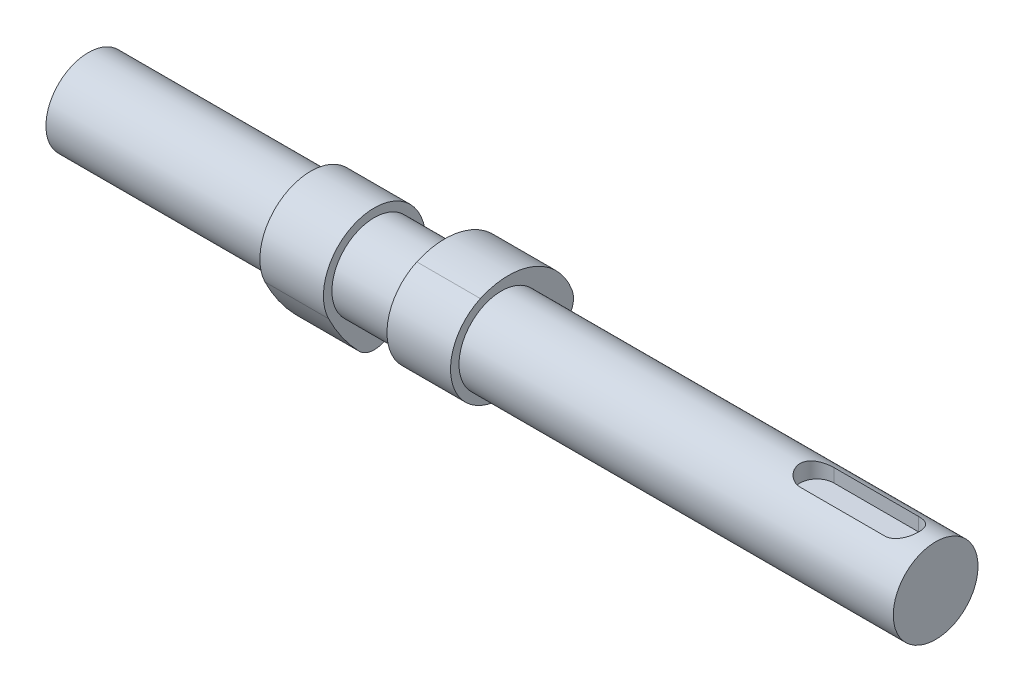
from build123d import *

# Parameters (mm, degrees)
SKETCH1_R                = 10
BOSS_EXTRUDE1_DEPTH      = 125
BOSS_EXTRUDE1_DEPTH_BACK = 75
BOSS_EXTRUDE2_START      = 15
BOSS_EXTRUDE2_DEPTH      = 7.5
LPATTERN1_COUNT          = 2
LPATTERN1_PITCH          = 30
BODY_MOVE_COPY1_ANGLE    = 90
CUT_EXTRUDE1_DEPTH       = 4


with BuildPart() as part:
    # Sketch1 → Boss-Extrude1 (new body, two sides)
    with BuildSketch(Plane(origin=(0, 0, 0), x_dir=(0, 0, -1), z_dir=(1, 0, 0))) as boss_extrude1_sk:
        Circle(SKETCH1_R)
    extrude(amount=BOSS_EXTRUDE1_DEPTH)
    extrude(boss_extrude1_sk.sketch, amount=-BOSS_EXTRUDE1_DEPTH_BACK)

    # Sketch3 → Cut-Extrude1 (cut)
    with BuildSketch(Plane(origin=(0, 10, 0), x_dir=(1, 0, 0), z_dir=(0, 1, 0))):
        with BuildLine():
            Line((97, 4), (117, 4))
            ThreePointArc((117, 4), (121, 0), (117, -4))
            Line((117, -4), (97, -4))
            ThreePointArc((97, -4), (93, 0), (97, 4))
        make_face()
    extrude(amount=-CUT_EXTRUDE1_DEPTH, mode=Mode.SUBTRACT)


with BuildPart() as body_2:
    # Sketch2 → Boss-Extrude2 (new body, symmetric)
    with BuildSketch(Plane(origin=(0, 0, 0), x_dir=(0, 0, -1), z_dir=(1, 0, 0)).offset(BOSS_EXTRUDE2_START)):
        with BuildLine():
            ThreePointArc((-4.950818385, 10.931120589), (-10.855235073, -5.115063196), (5.27814522, -10.776881879))
            ThreePointArc((5.27814522, -10.776881879), (10.675009162, -7.586625818), (15.507108825, -3.59229396))
            ThreePointArc((15.507108825, -3.59229396), (16.895326586, -1.149524968), (16.746983201, 1.656230392))
            ThreePointArc((16.746983201, 1.656230392), (7.939134659, 11.068540296), (-4.950818385, 10.931120589))
        make_face()
    boss_extrude2 = extrude(amount=BOSS_EXTRUDE2_DEPTH, both=True)


with BuildPart() as lpattern1_1:
    # LPattern1: Boss-Extrude2 ×2
    with Locations(*[(-i * LPATTERN1_PITCH, 0, 0) for i in range(1, LPATTERN1_COUNT)]):
        add(boss_extrude2)


with BuildPart() as lpattern1_1_1:
    # Body-Move/Copy1: moved
    add(lpattern1_1.part.rotate(Axis((0, 0, 0), (-1, 0, 0)), BODY_MOVE_COPY1_ANGLE))


solid = Compound([part.part, body_2.part, lpattern1_1_1.part])
